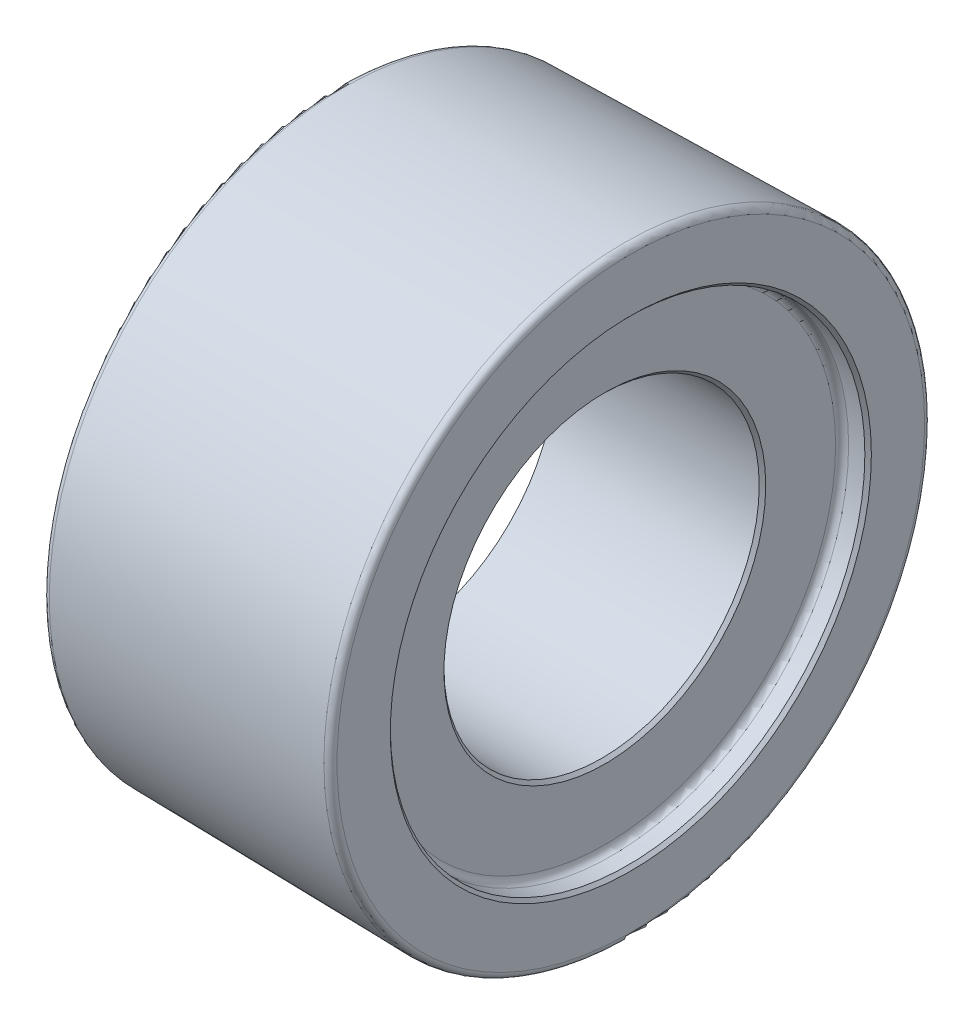
from build123d import *

# Parameters (mm, degrees)
VERRUNDUNG1_R = 1
FASE1_SIZE    = 0.5
VERRUNDUNG2_R = 1


with BuildPart() as part:
    # Skizze1 → Rotation1 (revolve)
    with BuildSketch(Plane.XY, mode=Mode.PRIVATE) as rotation1_sk:
        Polygon((0, -40.15), (0, -45.424522078), (45, -46.21), (45, -36.5), (41, -36.5), (41, -24.25), (9.17986928, -24.25), align=None)
    revolve(rotation1_sk.sketch.rotate(Axis((0, 0, 0), (1, 0, 0)), 270), axis=Axis((0, 0, 0), (1, 0, 0)))  # turned: the seam where the file's is

    # Verrundung1
    verrundung1_edges = [part.edges().sort_by_distance(p)[0] for p in [
        (45, 0, -46.21),
        (0, 0, -45.424522078),
    ]]
    fillet(verrundung1_edges, radius=VERRUNDUNG1_R)

    # Fase1
    fase1_edges = [part.edges().sort_by_distance(p)[0] for p in [
        (41, 0, -24.25),
        (45, 0, -36.5),
    ]]
    chamfer(fase1_edges, length=FASE1_SIZE)

    # Verrundung2
    verrundung2_edges = [part.edges().sort_by_distance(p)[0] for p in [
        (41, 0, -36.5),
    ]]
    fillet(verrundung2_edges, radius=VERRUNDUNG2_R)


solid = part.part
